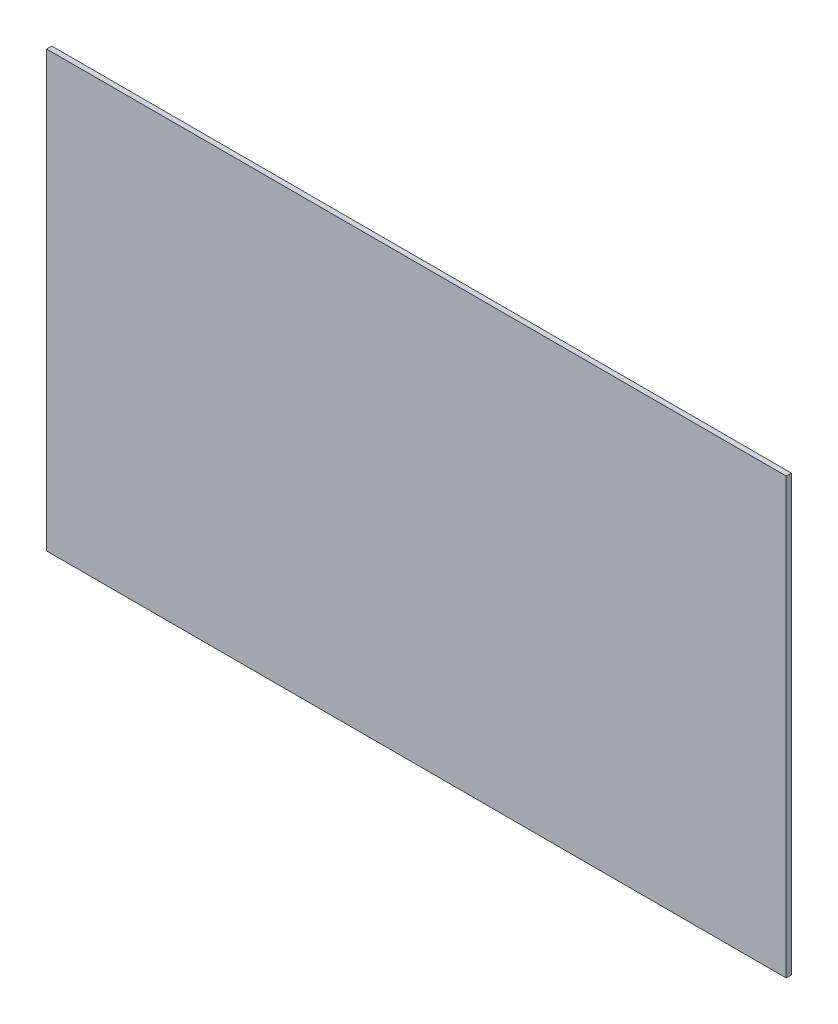
from build123d import *

# Parameters (mm, degrees)
SKETCH1_W      = 723.9
SKETCH1_H      = 425.45
EXTRUDE1_DEPTH = 2.54


with BuildPart() as part:
    # Sketch1 → Extrude1 (new body, symmetric)
    with BuildSketch(Plane.XY):
        with Locations((361.95, 212.725)):
            Rectangle(SKETCH1_W, SKETCH1_H)
    extrude(amount=EXTRUDE1_DEPTH, both=True)


solid = part.part
